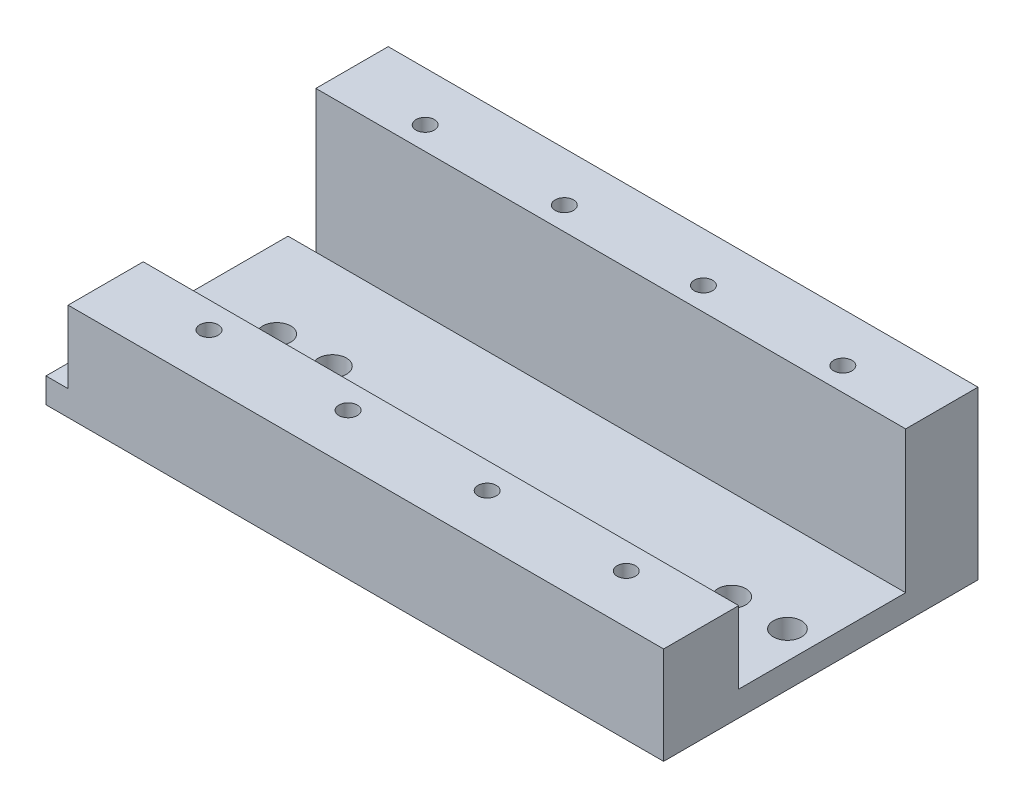
from build123d import *

# Parameters (mm, degrees)
SKETCH4_W                  = 106
SKETCH4_H                  = 30
BOSS_EXTRUDE2_DEPTH        = 13
M4X0_7_TAPPED_HOLE1_D      = 3.3
SKETCH28_W                 = 106
SKETCH28_H                 = 4.5
BOSS_EXTRUDE3_DEPTH        = 43.5
SKETCH32_W                 = 43.5
SKETCH32_H                 = 4.5
BOSS_EXTRUDE10_DEPTH       = 5
F_8_0_199_DIAMETER_HOLE1_D = 5.0546
SKETCH44_W                 = 107.027081708
SKETCH44_H                 = 13.5
BOSS_EXTRUDE17_DEPTH       = 13
M4X0_7_TAPPED_HOLE2_D      = 3.3


with BuildPart() as part:
    # Sketch4 → Boss-Extrude2 (new body)
    with BuildSketch(Plane.XY):
        with Locations((-36.891047602, -35.322762913)):
            Rectangle(SKETCH4_W, SKETCH4_H)
    extrude(amount=-BOSS_EXTRUDE2_DEPTH)

    # M4x0.7 Tapped Hole1 (through all)
    with Locations(Plane(origin=(-74.390985602, -20.322762913, -4.15), x_dir=(0, 0, 1), z_dir=(0, 1, 0))):
        with Locations((0, 0), (0, 25), (-0.055677319, 74.999938), (0, 50)):
            Hole(M4X0_7_TAPPED_HOLE1_D / 2)

    # Sketch28 → Boss-Extrude3 (add)
    with BuildSketch(Plane.XY):
        with Locations((-36.891047602, -48.072762913)):
            Rectangle(SKETCH28_W, SKETCH28_H)
    extrude(amount=BOSS_EXTRUDE3_DEPTH)

    # Sketch32 → Boss-Extrude10 (add)
    with BuildSketch(Plane.ZY.offset(89.891047602)):
        with Locations((21.75, -48.072762913)):
            Rectangle(SKETCH32_W, SKETCH32_H)
    extrude(amount=BOSS_EXTRUDE10_DEPTH)

    # #8 (0.199) Diameter Hole1 (through all)
    with Locations(Plane(origin=(-80.669073904, -45.822762913, 16.25), x_dir=(0, 0, 1), z_dir=(0, 1, 0))):
        with Locations((0, 0), (0, 91.778026302), (0, 81.778026302), (0, 10)):
            Hole(F_8_0_199_DIAMETER_HOLE1_D / 2)

    # Sketch44 → Boss-Extrude17 (add)
    with BuildSketch(Plane(origin=(0, -45.822762913, 0), x_dir=(1, 0, 0), z_dir=(0, 1, 0))):
        with Locations((-37.404588456, -36.75)):
            Rectangle(SKETCH44_W, SKETCH44_H)
    extrude(amount=BOSS_EXTRUDE17_DEPTH)

    # M4x0.7 Tapped Hole2 (through all)
    with Locations(Plane(origin=(-74.391047602, -32.822762913, 34.71), x_dir=(0, 0, 1), z_dir=(0, 1, 0))):
        with Locations((0, 0), (0, 25), (0, 50), (0, 75)):
            Hole(M4X0_7_TAPPED_HOLE2_D / 2)


solid = part.part
